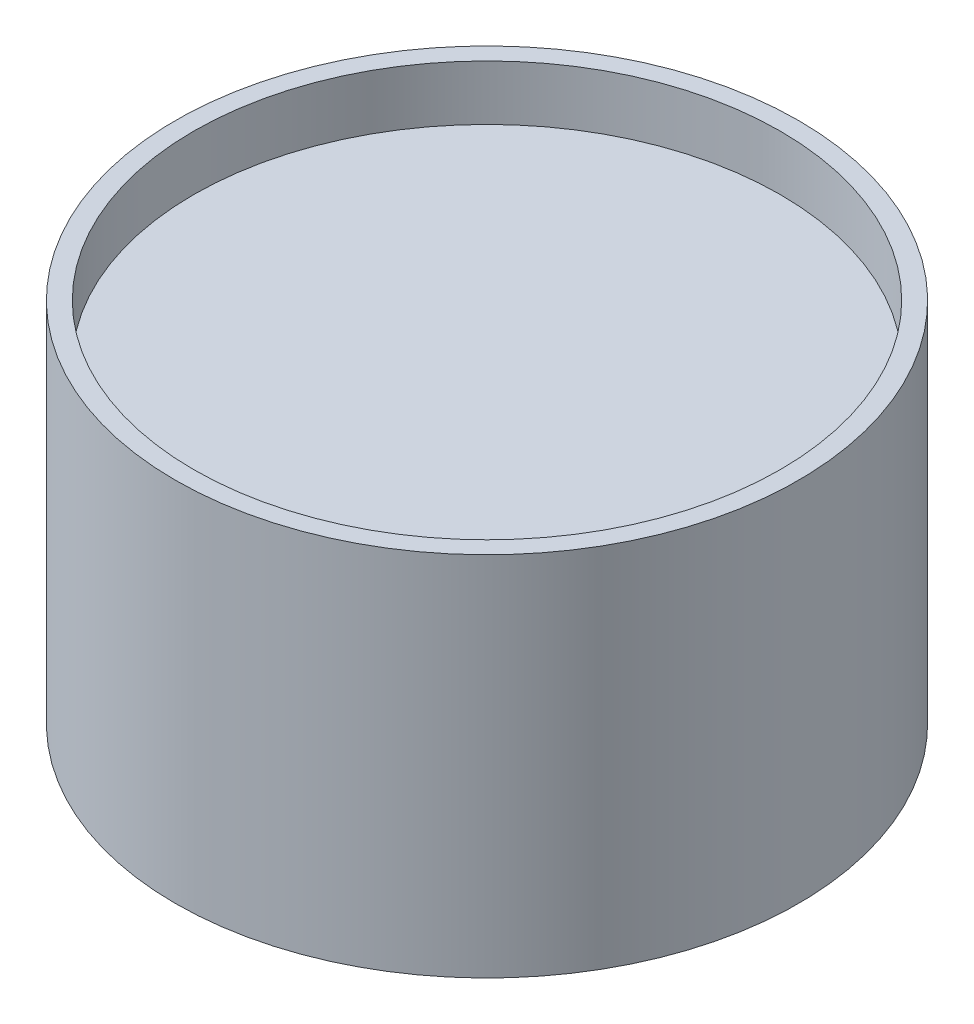
from build123d import *

# Parameters (mm, degrees)
SKETCH1_R           = 17
BOSS_EXTRUDE1_DEPTH = 20
SKETCH2_R           = 16
CUT_EXTRUDE1_DEPTH  = 3
SKETCH3_R           = 1
CUT_EXTRUDE2_DEPTH  = 2
FILLET1_R           = 1


with BuildPart() as part:
    # Sketch1 → Boss-Extrude1 (new body)
    with BuildSketch(Plane(origin=(0, 0, 0), x_dir=(1, 0, 0), z_dir=(0, 1, 0))):
        Circle(SKETCH1_R)
    extrude(amount=BOSS_EXTRUDE1_DEPTH)

    # Sketch2 → Cut-Extrude1 (cut)
    with BuildSketch(Plane(origin=(0, 20, 0), x_dir=(1, 0, 0), z_dir=(0, 1, 0))):
        Circle(SKETCH2_R)
    extrude(amount=-CUT_EXTRUDE1_DEPTH, mode=Mode.SUBTRACT)

    # Sketch3 → Cut-Extrude2 (cut)
    with BuildSketch(Plane.XZ):
        Circle(SKETCH3_R)
    extrude(amount=-CUT_EXTRUDE2_DEPTH, mode=Mode.SUBTRACT)

    # Fillet1
    fillet1_edges = [part.edges().sort_by_distance(p)[0] for p in [
        (-1, 2, 0),
    ]]
    fillet(fillet1_edges, radius=FILLET1_R)


solid = part.part
